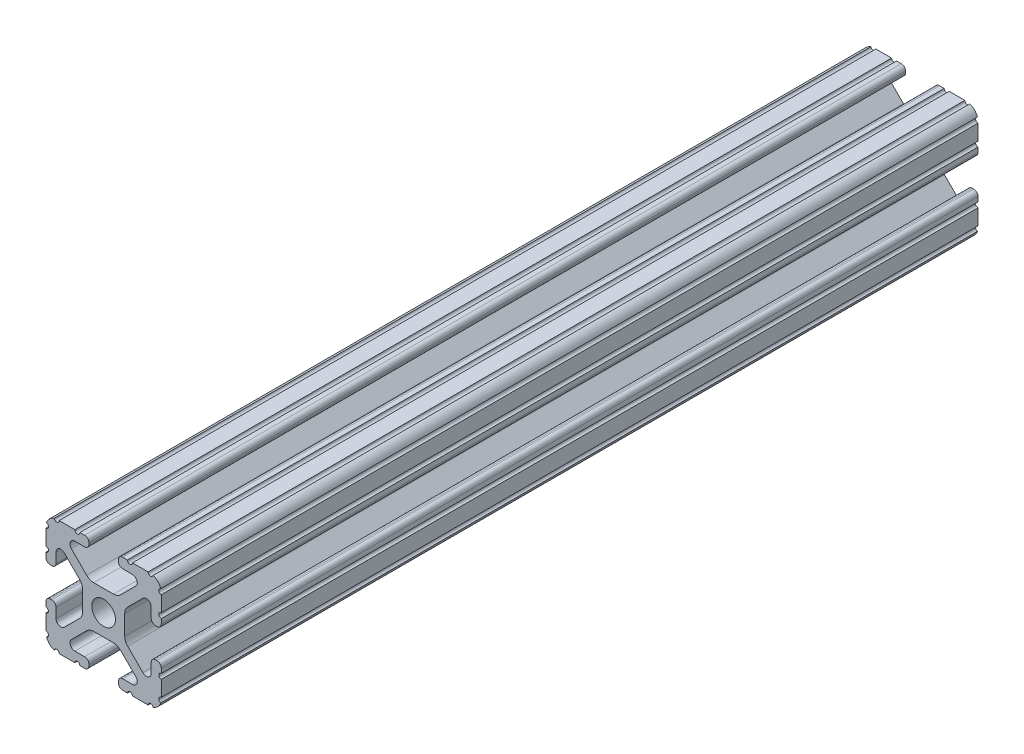
from build123d import *

# Parameters (mm, degrees)
BOSS_EXTRUDE1_DEPTH     = 90
SKETCH5_R               = 0.55245
CUT_EXTRUDE1_DEPTH      = 91
CUT_EXTRUDE1_DEPTH_BACK = 91


with BuildPart() as part:
    # Sketch4 → Boss-Extrude1 (new body, symmetric)
    with BuildSketch(Plane.XY):
        with BuildLine():
            Line((4.190365, -12.7), (10.11729625, -12.7))
            ThreePointArc((10.11729625, -12.7), (11.943543585, -11.943543585), (12.7, -10.11729625))
            Line((12.7, -10.11729625), (12.7, -4.190365))
            ThreePointArc((12.7, -4.190365), (12.42492494, -3.52627506), (11.760835, -3.2512))
            Line((11.760835, -3.2512), (11.429365, -3.2512))
            ThreePointArc((11.429365, -3.2512), (10.76527506, -3.52627506), (10.4902, -4.190365))
            Line((10.4902, -4.190365), (10.4902, -6.348478019))
            ThreePointArc((10.4902, -6.348478019), (9.830707141, -7.335478831), (8.666460301, -7.103895736))
            Line((8.666460301, -7.103895736), (5.299899128, -3.737334563))
            ThreePointArc((5.299899128, -3.737334563), (4.817571085, -3.015479634), (4.6482, -2.16399369))
            Line((4.6482, -2.16399369), (4.6482, 0))
            Line((4.6482, 0), (2.6035, 0))
            ThreePointArc((2.6035, 0), (1.840952505, -1.840952505), (0, -2.6035))
            Line((0, -2.6035), (0, -4.6482))
            Line((0, -4.6482), (2.16399369, -4.6482))
            ThreePointArc((2.16399369, -4.6482), (3.015479634, -4.817571085), (3.737334563, -5.299899128))
            Line((3.737334563, -5.299899128), (7.103895736, -8.666460301))
            ThreePointArc((7.103895736, -8.666460301), (7.335478831, -9.830707141), (6.348478019, -10.4902))
            Line((6.348478019, -10.4902), (4.190365, -10.4902))
            ThreePointArc((4.190365, -10.4902), (3.52627506, -10.76527506), (3.2512, -11.429365))
            Line((3.2512, -11.429365), (3.2512, -11.760835))
            ThreePointArc((3.2512, -11.760835), (3.52627506, -12.42492494), (4.190365, -12.7))
        make_face()
    extrude(amount=BOSS_EXTRUDE1_DEPTH, both=True)

    # Sketch5 → Cut-Extrude1 (cut, two sides)
    with BuildSketch(Plane.XY) as cut_extrude1_sk:
        with Locations((10.356153152, -12.7)):
            Circle(SKETCH5_R)
        with Locations((5.796028019, -12.7)):
            Circle(SKETCH5_R)
        with Locations((12.7, -10.356153152)):
            Circle(SKETCH5_R)
        with Locations((12.7, -5.796028019)):
            Circle(SKETCH5_R)
    extrude(amount=CUT_EXTRUDE1_DEPTH, mode=Mode.SUBTRACT)
    extrude(cut_extrude1_sk.sketch, amount=-CUT_EXTRUDE1_DEPTH_BACK, mode=Mode.SUBTRACT)

    # Mirror1: part across plane


with BuildPart() as part_1:
    add(part.part)
    add(part.part.mirror(Plane(origin=(0, 0, 0), x_dir=(0, 0, 1), z_dir=(1, 0, 0))))

    # Mirror2: part across plane


with BuildPart() as part_2:
    add(part_1.part)
    add(part_1.part.mirror(Plane.ZX))


solid = part_2.part
